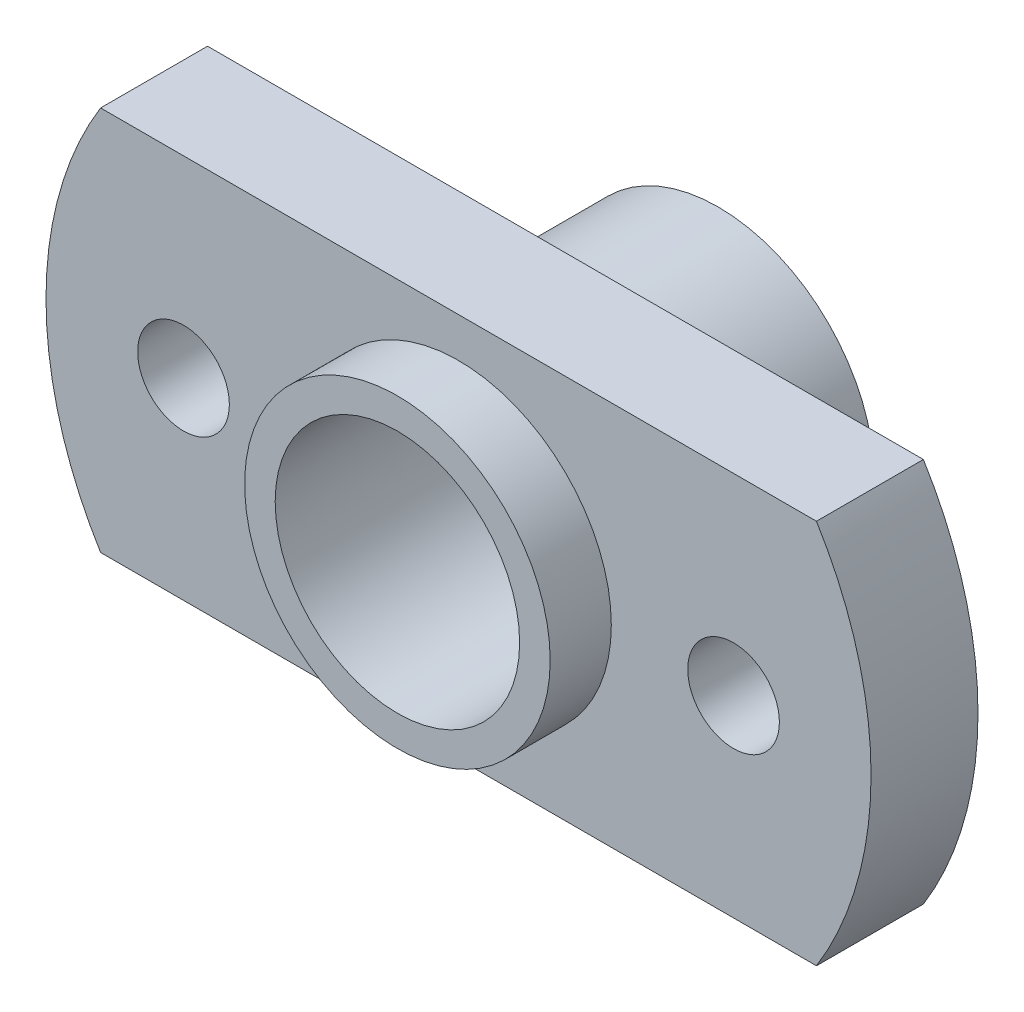
from build123d import *

# Parameters (mm, degrees)
BOSS_EXTRUDE1_DEPTH          = 3.5
SKETCH2_W                    = 5
SKETCH2_H                    = 2
SKETCH3_W                    = 5.1
SKETCH3_H                    = 5
F_3_0_3_DIAMETER_HOLE1_D     = 3
F_3_0_3_DIAMETER_HOLE1_DEPTH = 8.5
F_8_0_8_DIAMETER_HOLE1_D     = 8
F_8_0_8_DIAMETER_HOLE1_DEPTH = 10.5


with BuildPart() as part:
    # Sketch1 → Boss-Extrude1 (new body)
    with BuildSketch(Plane(origin=(0, 0, 177.026431985), x_dir=(-1, 0, 0), z_dir=(0, 0, -1))):
        with BuildLine():
            Line((177.813226718, -74.200057886), (154.386773282, -74.200057886))
            ThreePointArc((154.386773282, -74.200057886), (152.6, -80.500057886), (154.386773282, -86.800057886))
            Line((154.386773282, -86.800057886), (177.813226718, -86.800057886))
            ThreePointArc((177.813226718, -86.800057886), (179.6, -80.500057886), (177.813226718, -74.200057886))
        make_face()
    extrude(amount=-BOSS_EXTRUDE1_DEPTH)

    # Sketch2 → Revolve1 (revolve)
    with BuildSketch(Plane(origin=(0, -80.500057886, 0), x_dir=(1, 0, 0), z_dir=(0, 1, 0))):
        with Locations((-163.6, -181.526431985)):
            Rectangle(SKETCH2_W, SKETCH2_H)
    revolve(axis=Axis((-166.1, -80.500057886, 180.526431985), (0, 0, 1)))

    # Sketch3 → Revolve2 (revolve)
    with BuildSketch(Plane.XZ.offset(80.500057886)):
        with Locations((-163.55, 174.526431985)):
            Rectangle(SKETCH3_W, SKETCH3_H)
    revolve(axis=Axis((-166.1, -80.500057886, 177.026431985), (0, 0, -1)))

    # Ø3.0 (3) Diameter Hole1
    with Locations(Plane.XY.offset(180.526431985)):
        with Locations((-157.1, -80.500057886), (-175.1, -80.500057886)):
            Hole(F_3_0_3_DIAMETER_HOLE1_D / 2, depth=F_3_0_3_DIAMETER_HOLE1_DEPTH)

    # Ø8.0 (8) Diameter Hole1
    with Locations(Plane(origin=(0, 0, 172.026431985), x_dir=(-1, 0, 0), z_dir=(0, 0, -1))):
        with Locations((166.1, -80.500057886)):
            Hole(F_8_0_8_DIAMETER_HOLE1_D / 2, depth=F_8_0_8_DIAMETER_HOLE1_DEPTH)


solid = part.part
